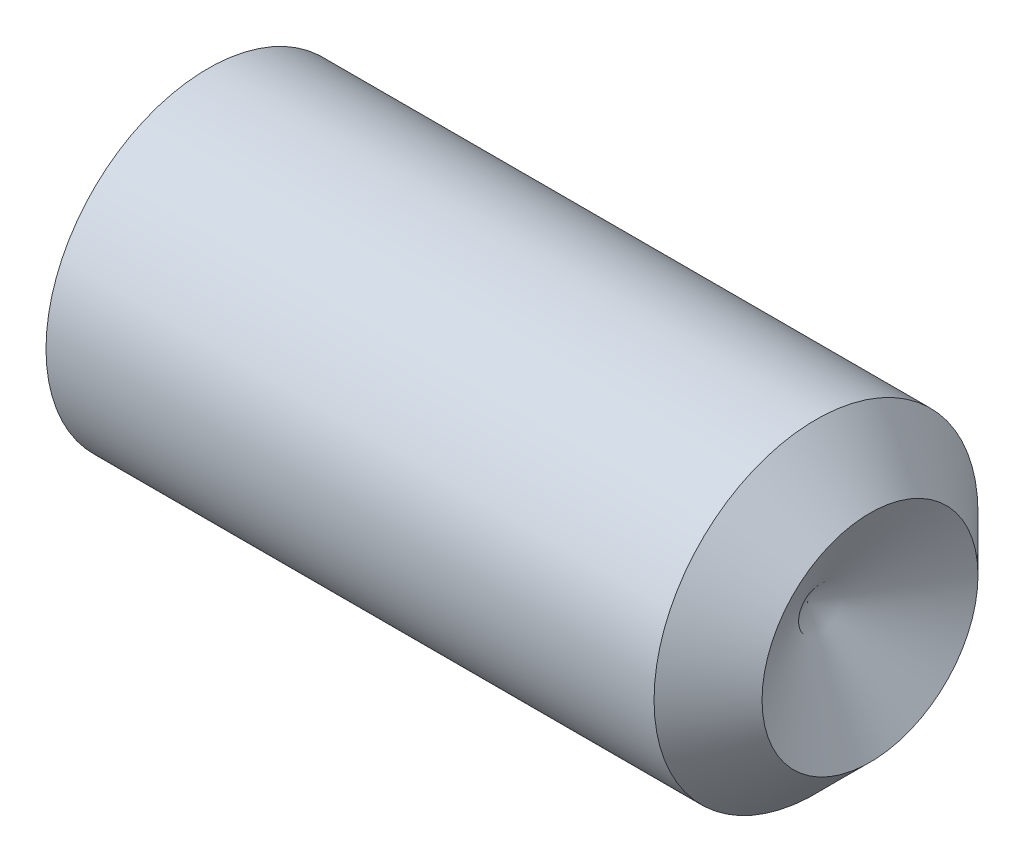
from build123d import *

# Parameters (mm, degrees)
HEX_2_DEPTH = 15


with BuildPart() as part:
    # BodySke → BaseBody (revolve)
    with BuildSketch(Plane.XY):
        Polygon((0, 0), (0, 10.352), (0.951473244, 12), (46, 12), (50, 8), (45.381197846, 0), align=None)
    revolve(axis=Axis((-12.7, 0, 0), (1, 0, 0)))

    # Sketch2 → Hex 2 (cut)
    with BuildSketch(Plane.ZY):
        Polygon((3.464101615, 6), (-3.464101615, 6), (-6.92820323, 0), (-3.464101615, -6), (3.464101615, -6), (6.92820323, 0), align=None)
    extrude(amount=-HEX_2_DEPTH, mode=Mode.SUBTRACT)


solid = part.part
